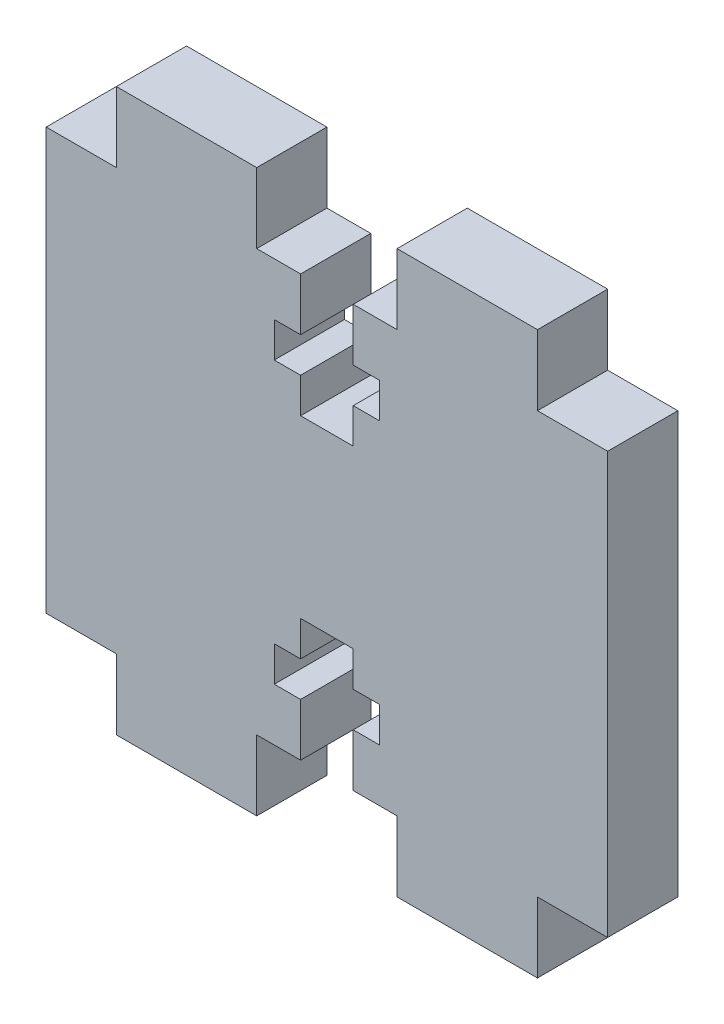
from build123d import *

# Parameters (mm, degrees)
BOSS_EXTRUDE1_DEPTH = 6.35


with BuildPart() as part:
    # Sketch1 → Boss-Extrude1 (new body)
    with BuildSketch(Plane.XY):
        Polygon((27.78125, 44.45), (31.75, 44.45), (31.75, 50.8), (44.45, 50.8), (44.45, 44.45), (50.8, 44.45), (50.8, 6.35), (44.45, 6.35), (44.45, 0), (31.75, 0), (31.75, 6.35), (27.78125, 6.35), (27.78125, 11.1125), (30.1625, 11.1125), (30.1625, 14.2875), (27.78125, 14.2875), (27.78125, 17.4625), (23.01875, 17.4625), (23.01875, 14.2875), (20.6375, 14.2875), (20.6375, 11.1125), (23.01875, 11.1125), (23.01875, 6.35), (19.05, 6.35), (19.05, 0), (6.35, 0), (6.35, 6.35), (0, 6.35), (0, 44.45), (6.35, 44.45), (6.35, 50.8), (19.05, 50.8), (19.05, 44.45), (23.01875, 44.45), (23.01875, 39.6875), (20.6375, 39.6875), (20.6375, 36.5125), (23.01875, 36.5125), (23.01875, 33.3375), (27.78125, 33.3375), (27.78125, 36.5125), (30.1625, 36.5125), (30.1625, 39.6875), (27.78125, 39.6875), align=None)
    extrude(amount=BOSS_EXTRUDE1_DEPTH)


solid = part.part
